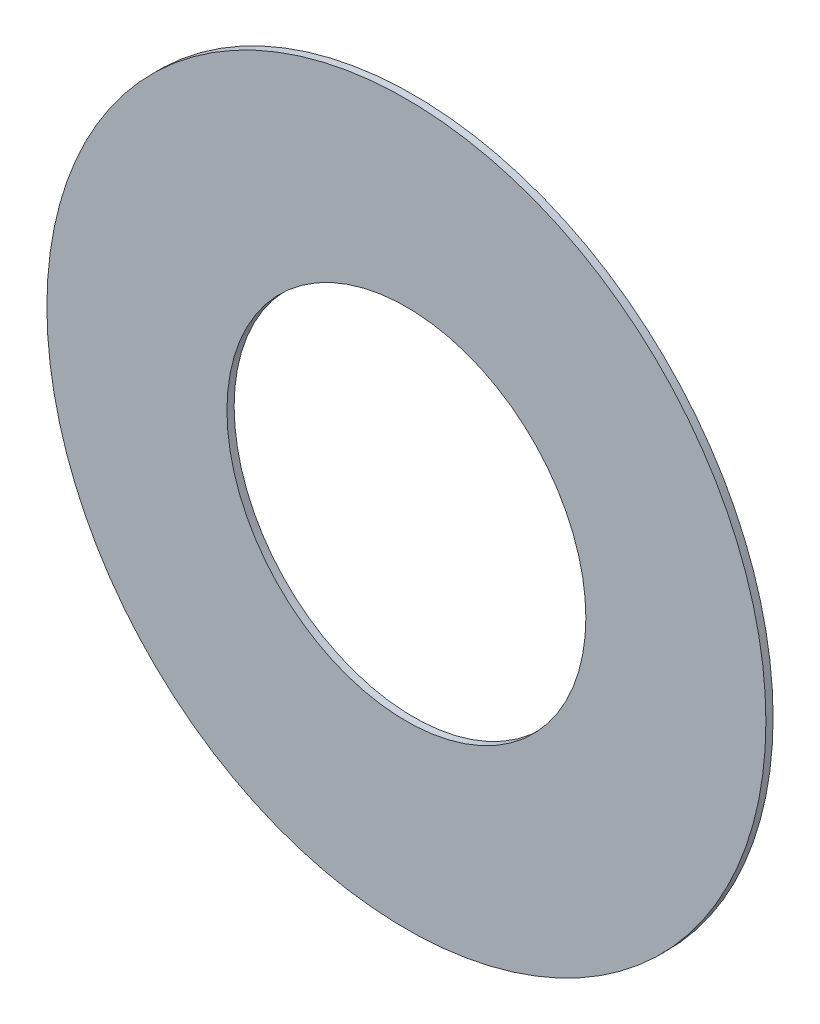
from build123d import *

# Parameters (mm, degrees)
SKETCH1_R           = 79.375
SKETCH1_R_2         = 39.624
BOSS_EXTRUDE1_DEPTH = 1.5875


with BuildPart() as part:
    # Sketch1 → Boss-Extrude1 (new body)
    with BuildSketch(Plane.XY):
        Circle(SKETCH1_R)
        Circle(SKETCH1_R_2, mode=Mode.SUBTRACT)
    extrude(amount=BOSS_EXTRUDE1_DEPTH)


solid = part.part
